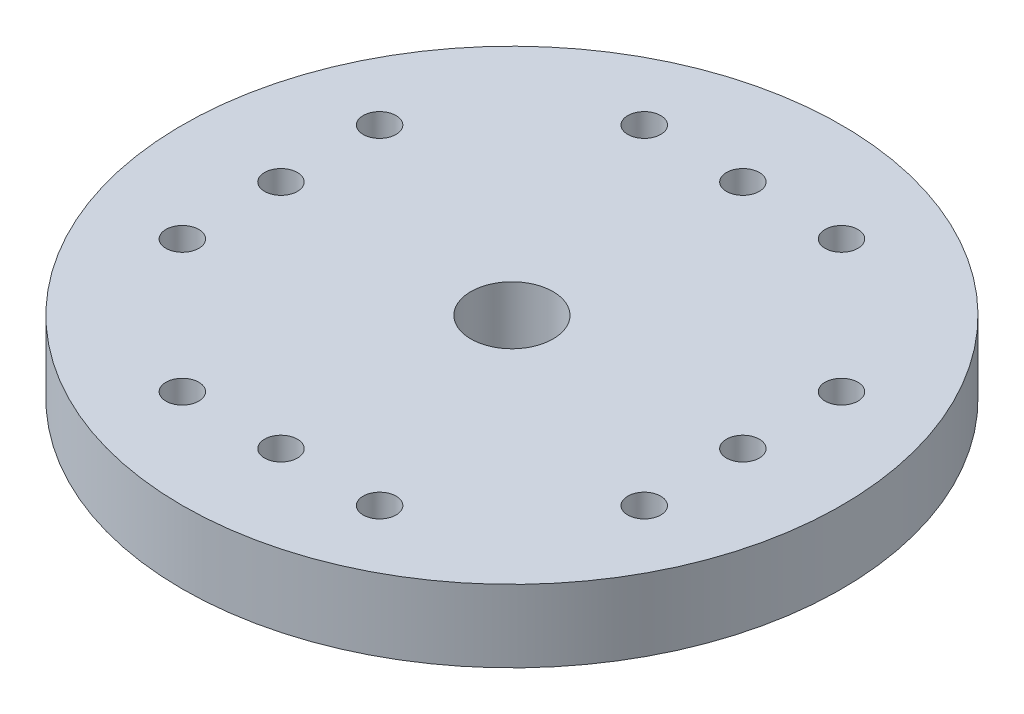
from build123d import *

# Parameters (mm, degrees)
SKETCH1_R           = 10.025
BOSS_EXTRUDE1_DEPTH = 2.2
SKETCH2_R           = 0.5
CUT_EXTRUDE1_DEPTH  = 3.2
SKETCH3_R           = 3.8
BOSS_EXTRUDE2_DEPTH = 3.4
SKETCH4_R           = 3
CUT_EXTRUDE2_DEPTH  = 2.8
SKETCH5_R           = 1.25
CUT_EXTRUDE3_DEPTH  = 3.8


with BuildPart() as part:
    # Sketch1 → Boss-Extrude1 (new body)
    with BuildSketch(Plane(origin=(0, 0, 0), x_dir=(1, 0, 0), z_dir=(0, 1, 0))):
        Circle(SKETCH1_R)
    extrude(amount=BOSS_EXTRUDE1_DEPTH)

    # Sketch2 → Cut-Extrude1 (cut, through all)
    with BuildSketch(Plane.XZ):
        with Locations((-7.025, -3)):
            Circle(SKETCH2_R)
        with Locations((-7.025, 0)):
            Circle(SKETCH2_R)
        with Locations((-7.025, 3)):
            Circle(SKETCH2_R)
        with Locations((-3, 7.025)):
            Circle(SKETCH2_R)
        with Locations((0, 7.025)):
            Circle(SKETCH2_R)
        with Locations((3, 7.025)):
            Circle(SKETCH2_R)
        with Locations((7.025, 3)):
            Circle(SKETCH2_R)
        with Locations((7.025, 0)):
            Circle(SKETCH2_R)
        with Locations((7.025, -3)):
            Circle(SKETCH2_R)
        with Locations((3, -7.025)):
            Circle(SKETCH2_R)
        with Locations((0, -7.025)):
            Circle(SKETCH2_R)
        with Locations((-3, -7.025)):
            Circle(SKETCH2_R)
    extrude(amount=-CUT_EXTRUDE1_DEPTH, mode=Mode.SUBTRACT)

    # Sketch3 → Boss-Extrude2 (add)
    with BuildSketch(Plane(origin=(0, 0, 0), x_dir=(-1, 0, 0), z_dir=(0, -1, 0))):
        Circle(SKETCH3_R)
    extrude(amount=BOSS_EXTRUDE2_DEPTH)

    # Sketch4 → Cut-Extrude2 (cut)
    with BuildSketch(Plane.XZ.offset(3.4)):
        Circle(SKETCH4_R)
    extrude(amount=-CUT_EXTRUDE2_DEPTH, mode=Mode.SUBTRACT)

    # Sketch5 → Cut-Extrude3 (cut, through all)
    with BuildSketch(Plane.XZ.offset(0.6)):
        Circle(SKETCH5_R)
    extrude(amount=-CUT_EXTRUDE3_DEPTH, mode=Mode.SUBTRACT)


solid = part.part
